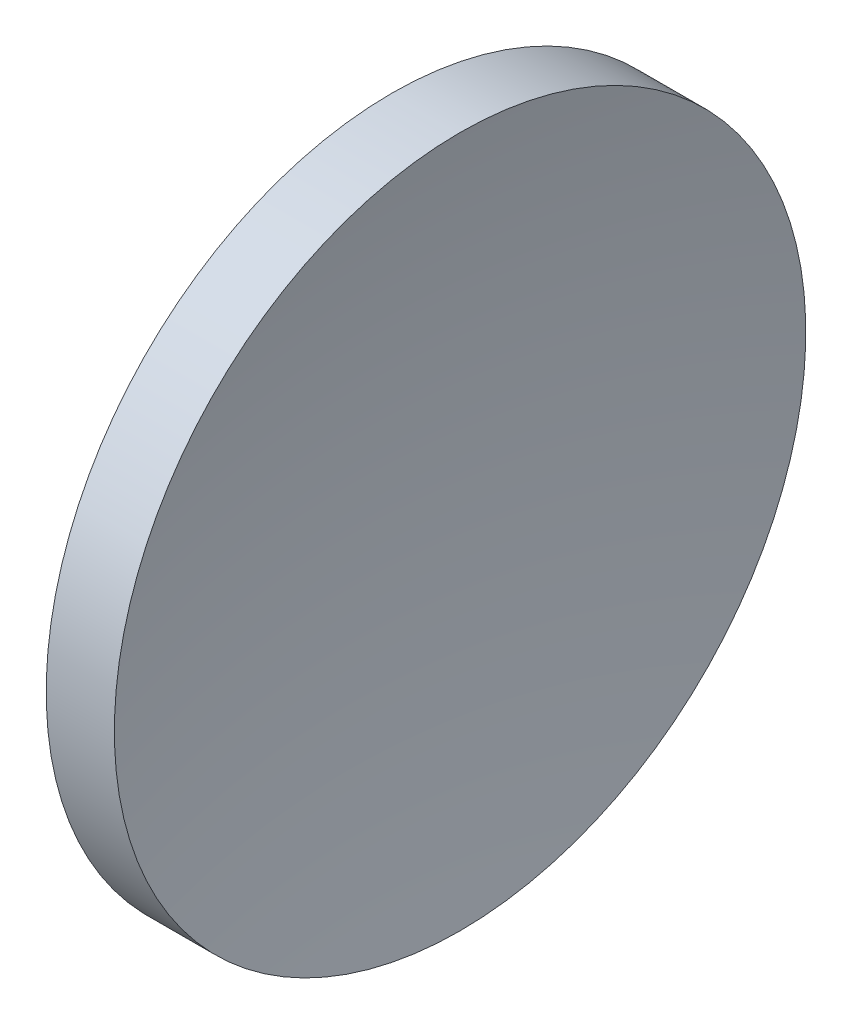
from build123d import *


with BuildPart() as part:
    # 草图1 → 旋转1 (revolve)
    with BuildSketch(Plane.XY):
        with BuildLine():
            Line((128.640850795, 77.716840471), (126.176652981, 77.716840471))
            ThreePointArc((126.176652981, 77.716840471), (123.520722541, 71.715982145), (122.612193698, 65.216840471))
            Line((122.612193698, 65.216840471), (127.412193483, 65.216840471))
            ThreePointArc((127.412193483, 65.216840471), (127.720096161, 71.496959872), (128.640850795, 77.716840471))
        make_face()
    revolve(axis=Axis((115.944491298, 65.216840471, 0), (1, 0, 0)))


solid = part.part
